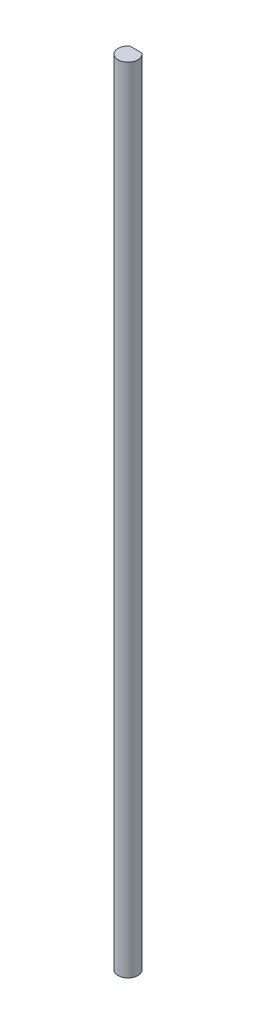
from build123d import *

# Parameters (mm, degrees)
BOSS_EXTRUDE1_DEPTH = 254


with BuildPart() as part:
    # Sketch1 → Boss-Extrude1 (new body)
    with BuildSketch(Plane(origin=(0, 0, 0), x_dir=(1, 0, 0), z_dir=(0, 1, 0))):
        with BuildLine():
            Line((-1.905, 2.54), (1.905, 2.54))
            ThreePointArc((1.905, 2.54), (0, -3.175), (-1.905, 2.54))
        make_face()
    extrude(amount=BOSS_EXTRUDE1_DEPTH)


solid = part.part
